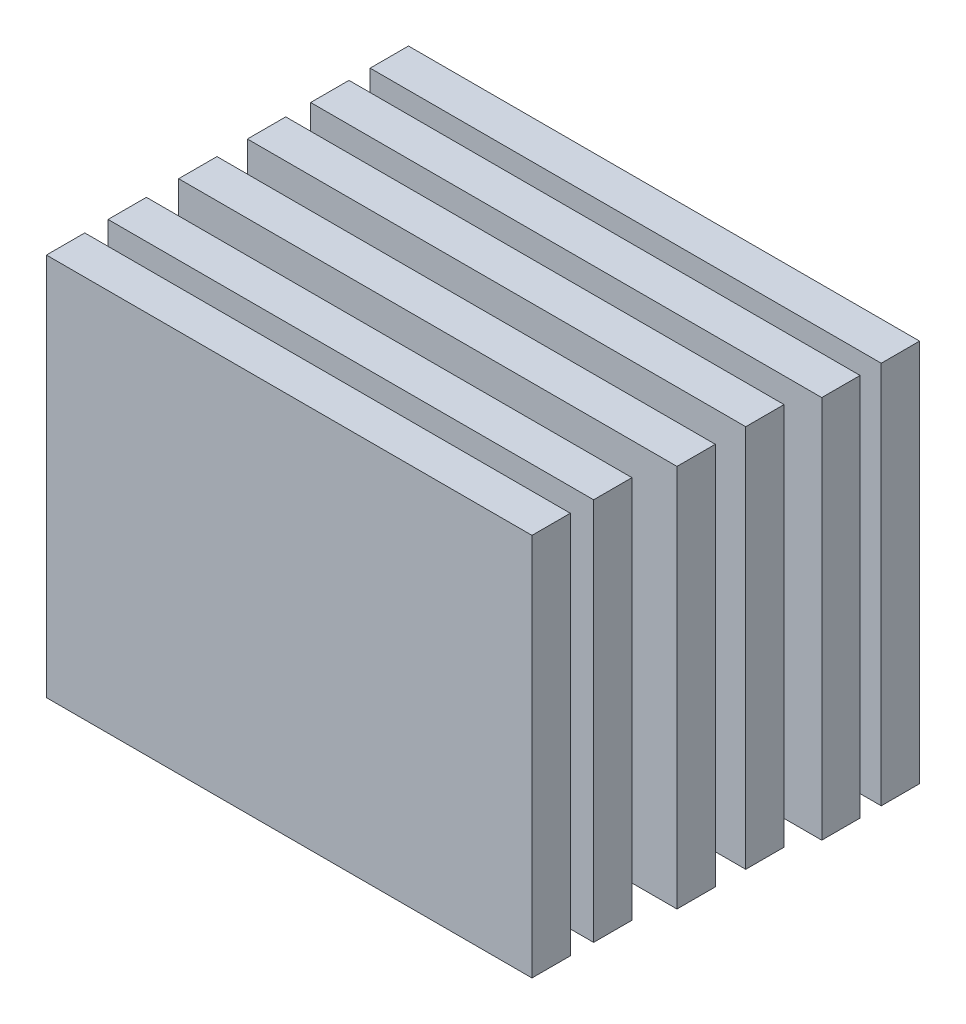
from build123d import *

# Parameters (mm, degrees)
SKETCH1_W             = 39
SKETCH1_H             = 3
BOSS_EXTRUDE1_DEPTH   = 30
SKETCH1_W_2           = 38
BOSS_EXTRUDE1_2_DEPTH = 30
BOSS_EXTRUDE1_3_DEPTH = 30
SKETCH1_W_3           = 40
BOSS_EXTRUDE1_4_DEPTH = 30
BOSS_EXTRUDE1_5_DEPTH = 30
BOSS_EXTRUDE1_6_DEPTH = 30


with BuildPart() as part:
    # Sketch1 → Boss-Extrude1 (new body)
    with BuildSketch(Plane(origin=(0, 0, 0), x_dir=(1, 0, 0), z_dir=(0, 1, 0))):
        with Locations((19.5, -1.5)):
            Rectangle(SKETCH1_W, SKETCH1_H)
    extrude(amount=BOSS_EXTRUDE1_DEPTH)


with BuildPart() as body_2:
    # Sketch1 → Boss-Extrude1 2 (new body)
    with BuildSketch(Plane(origin=(0, 0, 0), x_dir=(1, 0, 0), z_dir=(0, 1, 0))):
        with Locations((19, -7.023809524)):
            Rectangle(SKETCH1_W_2, SKETCH1_H)
    extrude(amount=BOSS_EXTRUDE1_2_DEPTH)


with BuildPart() as body_3:
    # Sketch1 → Boss-Extrude1 3 (new body)
    with BuildSketch(Plane(origin=(0, 0, 0), x_dir=(1, 0, 0), z_dir=(0, 1, 0))):
        with Locations((19.5, 3.880952381)):
            Rectangle(SKETCH1_W, SKETCH1_H)
    extrude(amount=BOSS_EXTRUDE1_3_DEPTH)


with BuildPart() as body_4:
    # Sketch1 → Boss-Extrude1 4 (new body)
    with BuildSketch(Plane(origin=(0, 0, 0), x_dir=(1, 0, 0), z_dir=(0, 1, 0))):
        with Locations((20, 8.83061545)):
            Rectangle(SKETCH1_W_3, SKETCH1_H)
    extrude(amount=BOSS_EXTRUDE1_4_DEPTH)


with BuildPart() as body_5:
    # Sketch1 → Boss-Extrude1 5 (new body)
    with BuildSketch(Plane(origin=(0, 0, 0), x_dir=(1, 0, 0), z_dir=(0, 1, 0))):
        with Locations((19, -11.847788313)):
            Rectangle(SKETCH1_W_2, SKETCH1_H)
    extrude(amount=BOSS_EXTRUDE1_5_DEPTH)


with BuildPart() as body_6:
    # Sketch1 → Boss-Extrude1 6 (new body)
    with BuildSketch(Plane(origin=(0, 0, 0), x_dir=(1, 0, 0), z_dir=(0, 1, 0))):
        with Locations((20, 13.486479069)):
            Rectangle(SKETCH1_W_3, SKETCH1_H)
    extrude(amount=BOSS_EXTRUDE1_6_DEPTH)


solid = Compound([part.part, body_2.part, body_3.part, body_4.part, body_5.part, body_6.part])
